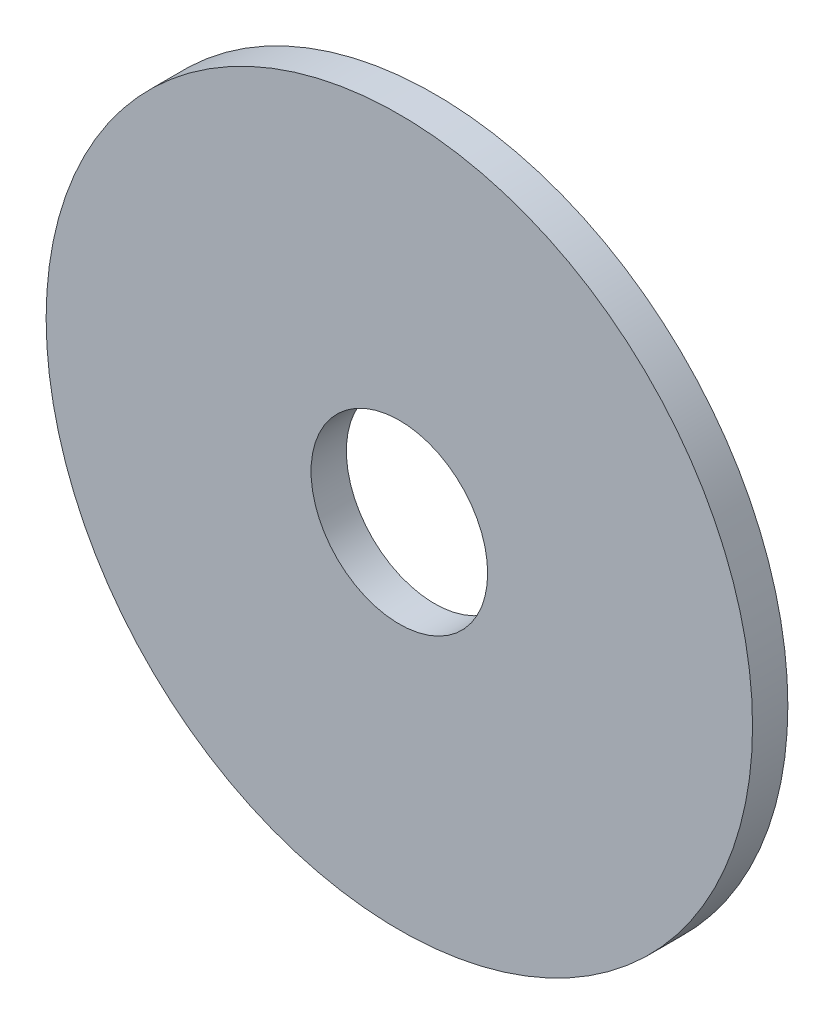
from build123d import *

# Parameters (mm, degrees)
SKETCH1_R           = 20
BOSS_EXTRUDE1_DEPTH = 2
SKETCH2_R           = 5
CUT_EXTRUDE1_DEPTH  = 4


with BuildPart() as part:
    # Sketch1 → Boss-Extrude1 (new body)
    with BuildSketch(Plane.XY):
        Circle(SKETCH1_R)
    extrude(amount=BOSS_EXTRUDE1_DEPTH)

    # Sketch2 → Cut-Extrude1 (cut)
    with BuildSketch(Plane.XY.offset(2)):
        Circle(SKETCH2_R)
    extrude(amount=-CUT_EXTRUDE1_DEPTH, mode=Mode.SUBTRACT)


solid = part.part
